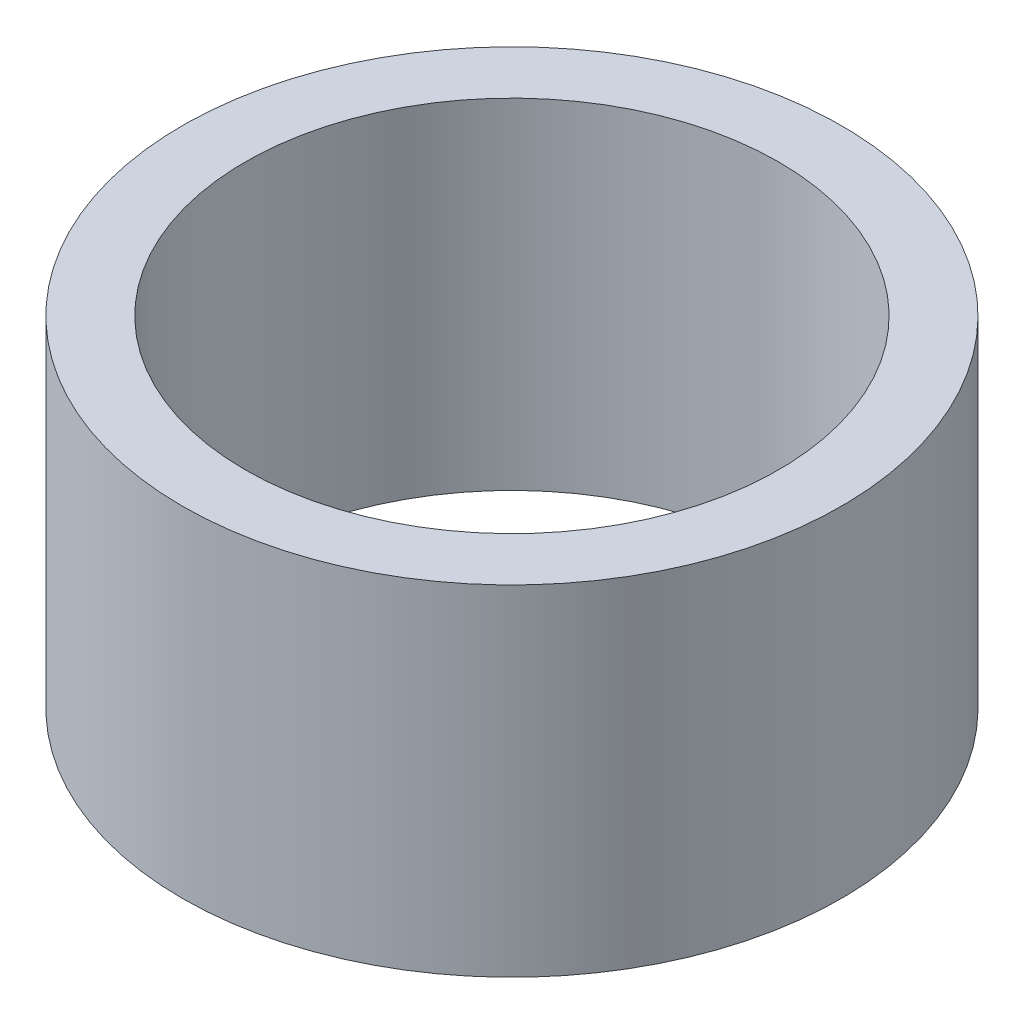
from build123d import *

# Parameters (mm, degrees)
SKETCH_1_R      = 4.85
SKETCH_1_R_2    = 3.925
EXTRUDE_1_DEPTH = 5


with BuildPart() as part:
    # 草图1 → 凸台-拉伸1 (new body)
    with BuildSketch(Plane(origin=(0, 0, 0), x_dir=(1, 0, 0), z_dir=(0, 1, 0))):
        Circle(SKETCH_1_R)
        Circle(SKETCH_1_R_2, mode=Mode.SUBTRACT)
    extrude(amount=EXTRUDE_1_DEPTH)


solid = part.part
